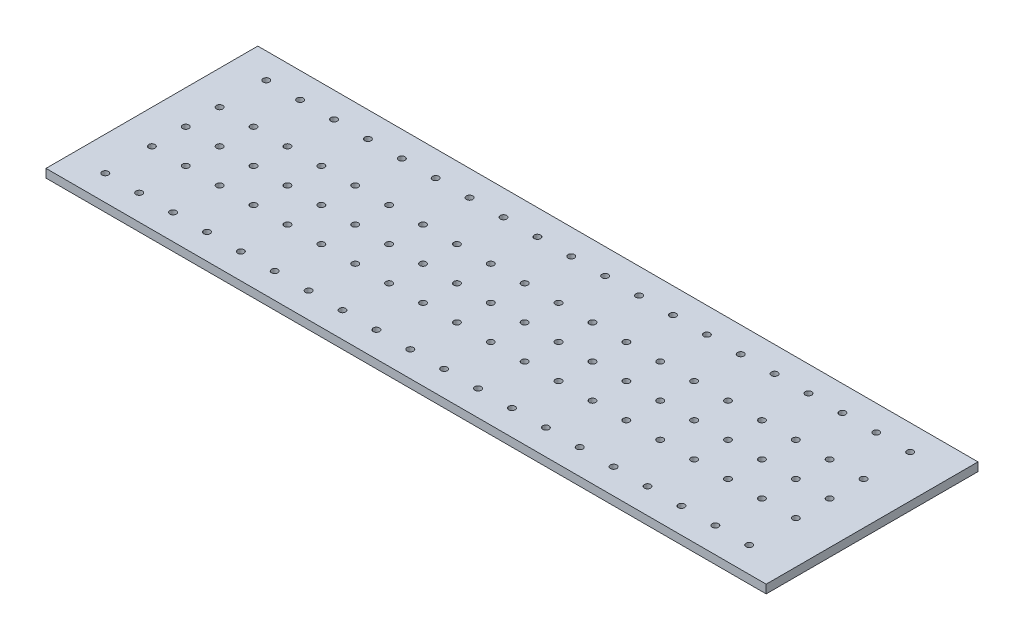
from build123d import *

# Parameters (mm, degrees)
SKETCH1_W           = 850
SKETCH1_H           = 250
BOSS_EXTRUDE1_DEPTH = 10
SKETCH2_R           = 3.75
CUT_EXTRUDE1_DEPTH  = 10
LPATTERN1_COUNT     = 20
LPATTERN1_PITCH     = 40


with BuildPart() as part:
    # Sketch1 → Boss-Extrude1 (new body)
    with BuildSketch(Plane(origin=(0, 0, 0), x_dir=(1, 0, 0), z_dir=(0, 1, 0))):
        Rectangle(SKETCH1_W, SKETCH1_H)
    extrude(amount=BOSS_EXTRUDE1_DEPTH)

    # Sketch2 → Cut-Extrude1 (cut)
    with BuildSketch(Plane(origin=(0, 10, 0), x_dir=(1, 0, 0), z_dir=(0, 1, 0))):
        with Locations((-385.057285496, 95)):
            Circle(SKETCH2_R)
        with Locations((-385.057285496, 0)):
            Circle(SKETCH2_R)
        with Locations((-385.057285496, -95)):
            Circle(SKETCH2_R)
        with Locations((-385.057285496, 40)):
            Circle(SKETCH2_R)
        with Locations((-385.057285496, -40)):
            Circle(SKETCH2_R)
    cut_extrude1 = extrude(amount=-CUT_EXTRUDE1_DEPTH, mode=Mode.SUBTRACT)

    # LPattern1: Cut-Extrude1 ×20
    with Locations(*[(i * LPATTERN1_PITCH, 0, 0) for i in range(1, LPATTERN1_COUNT)]):
        add(cut_extrude1, mode=Mode.SUBTRACT)


solid = part.part
